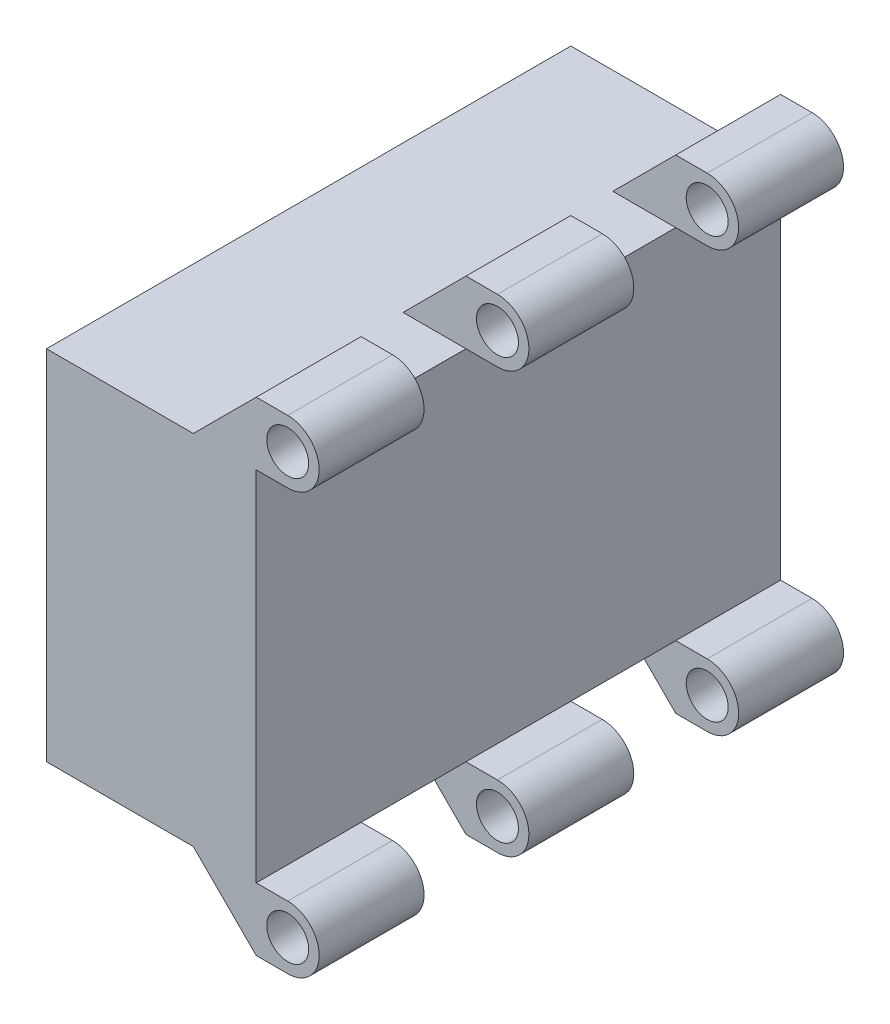
from build123d import *

# Parameters (mm, degrees)
SKETCH1_W               = 50
SKETCH1_H               = 34.11
BOSS_EXTRUDE1_DEPTH     = 20
SKETCH2_R               = 2
BOSS_EXTRUDE2_DEPTH     = 10
LPATTERN1_COUNT         = 3
LPATTERN1_PITCH         = 20
MIRROR1_COPY_1_SKETCH_R = 2
MIRROR1_COPY_1_DEPTH    = 10
MIRROR1_COPY_2_SKETCH_R = 2
MIRROR1_COPY_2_DEPTH    = 10
SKETCH3_R               = 8
SKETCH3_W               = 3
SKETCH3_H               = 30
CUT_EXTRUDE1_DEPTH      = 10


with BuildPart() as part:
    # Sketch1 → Boss-Extrude1 (new body)
    with BuildSketch(Plane(origin=(0, 0, 0), x_dir=(0, 0, -1), z_dir=(1, 0, 0))):
        with Locations((25, 17.055)):
            Rectangle(SKETCH1_W, SKETCH1_H)
    extrude(amount=BOSS_EXTRUDE1_DEPTH)

    # Sketch2 → Boss-Extrude2 (add)
    with BuildSketch(Plane.XY):
        with BuildLine():
            Line((20, 34.11), (23, 34.11))
            ThreePointArc((23, 34.11), (26, 37.11), (23, 40.11))
            Line((23, 40.11), (20, 40.11))
            Line((20, 40.11), (14, 34.11))
            Line((14, 34.11), (20, 34.11))
        make_face()
        with Locations((23, 37.11)):
            Circle(SKETCH2_R, mode=Mode.SUBTRACT)
    boss_extrude2 = extrude(amount=-BOSS_EXTRUDE2_DEPTH)

    # LPattern1: Boss-Extrude2 ×3
    with Locations(*[(0, 0, -i * LPATTERN1_PITCH) for i in range(1, LPATTERN1_COUNT)]):
        add(boss_extrude2)

    # Mirror1: Boss-Extrude2 across plane
    add(boss_extrude2.mirror(Plane.ZX.offset(17.055)))

    # Mirror1 copy 1 sketch → Mirror1 copy 1 (add)
    with BuildSketch(Plane(origin=(0, 34.11, -20), x_dir=(1, 0, 0), z_dir=(0, 0, 1))):
        with BuildLine():
            Line((20, -34.11), (23, -34.11))
            ThreePointArc((23, -34.11), (26, -37.11), (23, -40.11))
            Line((23, -40.11), (20, -40.11))
            Line((20, -40.11), (14, -34.11))
            Line((14, -34.11), (20, -34.11))
        make_face()
        with Locations((23, -37.11)):
            Circle(MIRROR1_COPY_1_SKETCH_R, mode=Mode.SUBTRACT)
    extrude(amount=-MIRROR1_COPY_1_DEPTH)

    # Mirror1 copy 2 sketch → Mirror1 copy 2 (add)
    with BuildSketch(Plane(origin=(0, 34.11, -40), x_dir=(1, 0, 0), z_dir=(0, 0, 1))):
        with BuildLine():
            Line((20, -34.11), (23, -34.11))
            ThreePointArc((23, -34.11), (26, -37.11), (23, -40.11))
            Line((23, -40.11), (20, -40.11))
            Line((20, -40.11), (14, -34.11))
            Line((14, -34.11), (20, -34.11))
        make_face()
        with Locations((23, -37.11)):
            Circle(MIRROR1_COPY_2_SKETCH_R, mode=Mode.SUBTRACT)
    extrude(amount=-MIRROR1_COPY_2_DEPTH)

    # Sketch3 → Cut-Extrude1 (cut)
    with BuildSketch(Plane.ZY):
        with Locations((-25, 17.055)):
            Circle(SKETCH3_R)
        with Locations((-39, 17.055)):
            Rectangle(SKETCH3_W, SKETCH3_H)
        with Locations((-11, 17.055)):
            Rectangle(SKETCH3_W, SKETCH3_H)
    extrude(amount=-CUT_EXTRUDE1_DEPTH, mode=Mode.SUBTRACT)


solid = part.part
